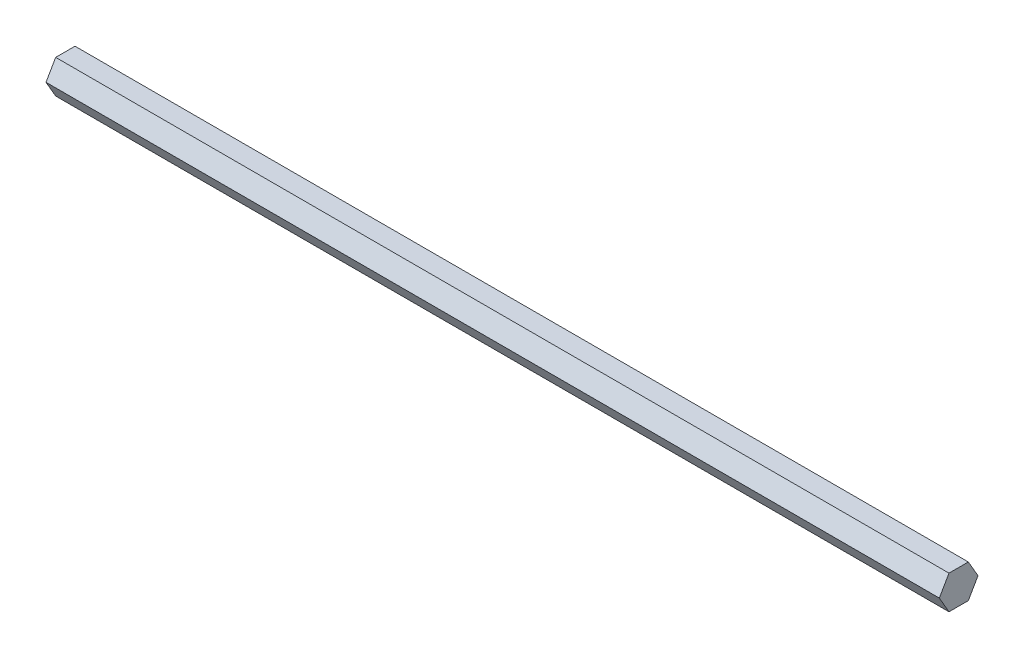
from build123d import *

# Parameters (mm, degrees)
BOSS_EXTRUDE1_DEPTH = 127


with BuildPart() as part:
    # Sketch1 → Boss-Extrude1 (new body, symmetric)
    with BuildSketch(Plane(origin=(0, 0, 0), x_dir=(0, 0, -1), z_dir=(1, 0, 0))):
        Polygon((2.749630657, -4.7625), (5.499261314, 0), (2.749630657, 4.7625), (-2.749630657, 4.7625), (-5.499261314, 0), (-2.749630657, -4.7625), align=None)
    extrude(amount=BOSS_EXTRUDE1_DEPTH, both=True)


solid = part.part
